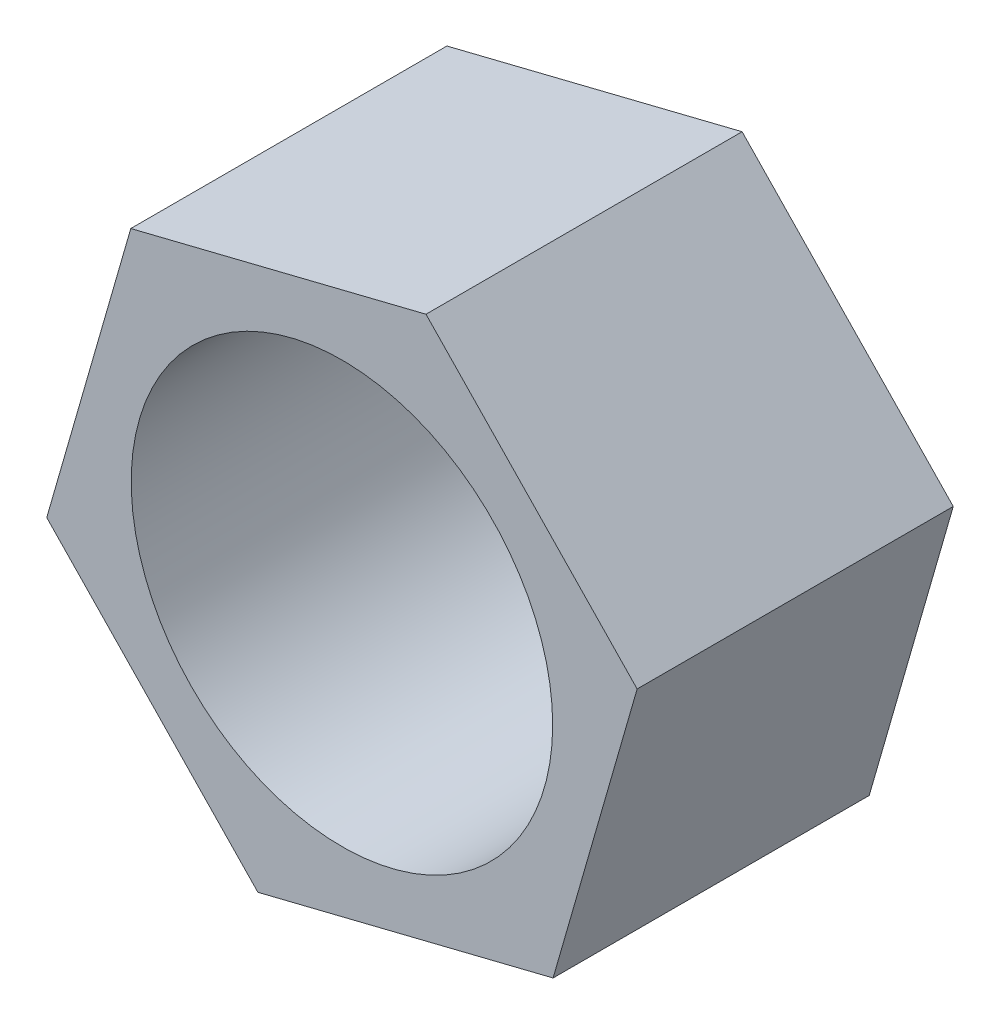
from build123d import *

# Parameters (mm, degrees)
SKETCH1_R           = 2
BOSS_EXTRUDE1_DEPTH = 3


with BuildPart() as part:
    # Sketch1 → Boss-Extrude1 (new body)
    with BuildSketch(Plane.XY):
        Polygon((2.003796793, -2.078011489), (2.801509135, 0.696333182), (0.797712342, 2.774344671), (-2.003796793, 2.078011489), (-2.801509135, -0.696333182), (-0.797712342, -2.774344671), align=None)
        Circle(SKETCH1_R, mode=Mode.SUBTRACT)
    extrude(amount=BOSS_EXTRUDE1_DEPTH)


solid = part.part
